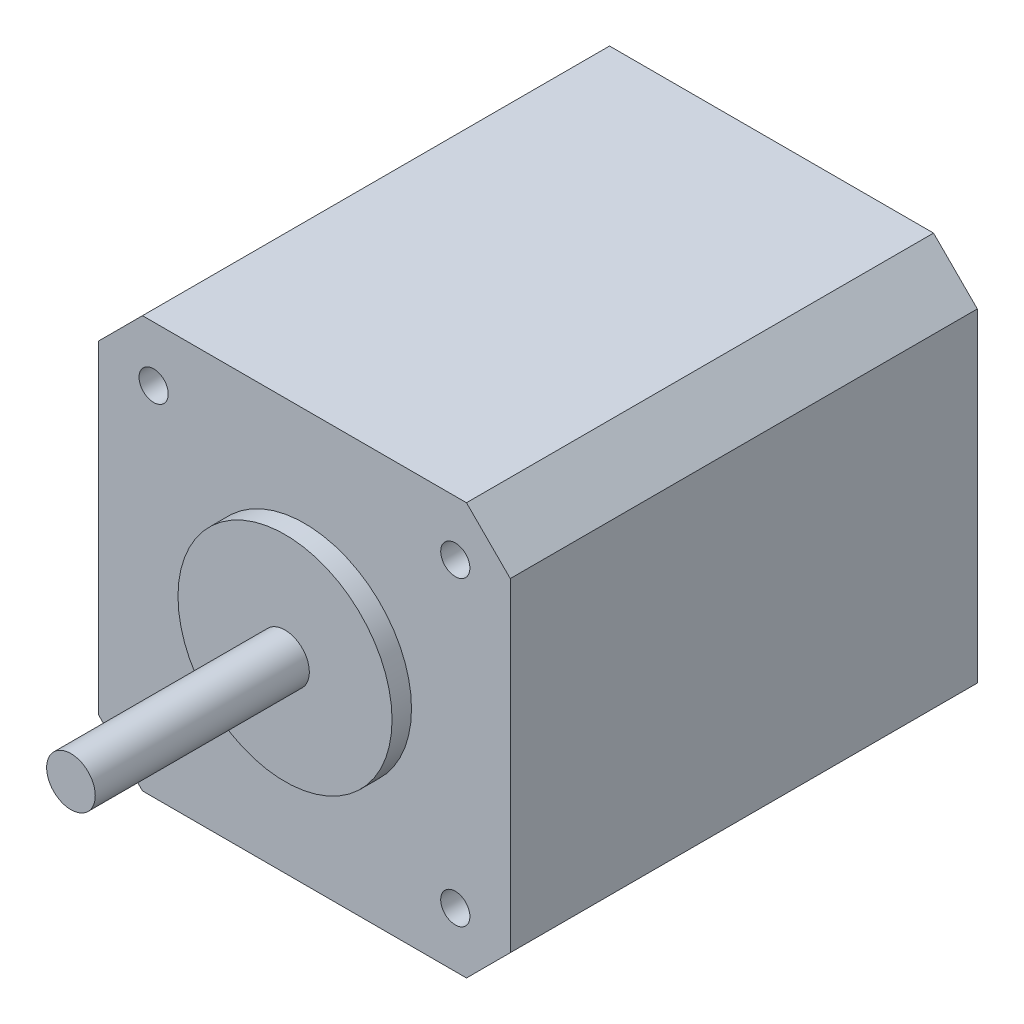
from build123d import *

# Parameters (mm, degrees)
SKETCH1_W           = 42.3
SKETCH1_H           = 42.3
SKETCH1_R           = 1.5
BOSS_EXTRUDE1_DEPTH = 48
SKETCH2_R           = 11
BOSS_EXTRUDE2_DEPTH = 2
SKETCH3_R           = 2.5
BOSS_EXTRUDE3_DEPTH = 22
CHAMFER1_SIZE       = 4.5


with BuildPart() as part:
    # Sketch1 → Boss-Extrude1 (new body)
    with BuildSketch(Plane.XY):
        Rectangle(SKETCH1_W, SKETCH1_H)
        with Locations((-15.5, 15.5)):
            Circle(SKETCH1_R, mode=Mode.SUBTRACT)
        with Locations((15.5, 15.5)):
            Circle(SKETCH1_R, mode=Mode.SUBTRACT)
        with Locations((-15.5, -15.5)):
            Circle(SKETCH1_R, mode=Mode.SUBTRACT)
        with Locations((15.5, -15.5)):
            Circle(SKETCH1_R, mode=Mode.SUBTRACT)
    extrude(amount=BOSS_EXTRUDE1_DEPTH)

    # Sketch2 → Boss-Extrude2 (add)
    with BuildSketch(Plane.XY.offset(48)):
        Circle(SKETCH2_R)
    extrude(amount=BOSS_EXTRUDE2_DEPTH)

    # Sketch3 → Boss-Extrude3 (add)
    with BuildSketch(Plane.XY.offset(50)):
        Circle(SKETCH3_R)
    extrude(amount=BOSS_EXTRUDE3_DEPTH)

    # Chamfer1
    chamfer1_edges = [part.edges().sort_by_distance(p)[0] for p in [
        (-21.15, 21.15, 24),
        (21.15, 21.15, 24),
        (21.15, -21.15, 24),
        (-21.15, -21.15, 24),
    ]]
    chamfer(chamfer1_edges, length=CHAMFER1_SIZE)


solid = part.part
